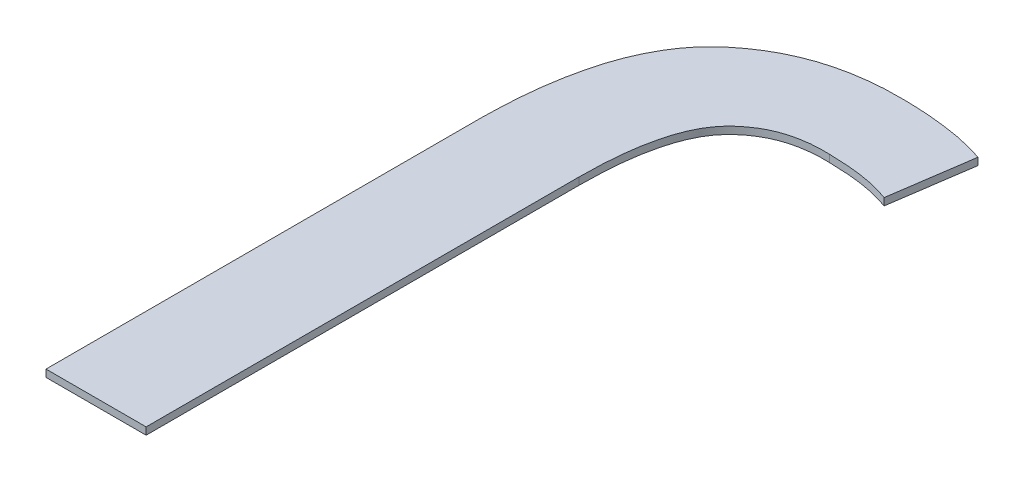
from build123d import *

# Parameters (mm, degrees)
EXTRUDE_1_DEPTH = 0.006


with BuildPart() as part:
    # Эскиз1 → Бобышка-Вытянуть1 (new body)
    with BuildSketch(Plane(origin=(0, 0, 0), x_dir=(1, 0, 0), z_dir=(0, 1, 0))):
        with BuildLine():
            Line((-0.552273294, -0.207212096), (-0.469416036, -0.207212096))
            Line((-0.469416036, -0.207212096), (-0.469416036, 0.15108915))
            add(Edge.make_bspline(
                [(-0.469416036, 0.15108915), (-0.469337668, 0.156710765), (-0.469187031, 0.167516567), (-0.468051363, 0.183019987), (-0.46630937, 0.197186892), (-0.463608191, 0.209875156), (-0.460547741, 0.221272508), (-0.456571693, 0.23120128), (-0.451914296, 0.239795103), (-0.446397888, 0.246954712), (-0.440258107, 0.252955311), (-0.433597544, 0.258071325), (-0.42638389, 0.262405578), (-0.418587315, 0.265910913), (-0.410168879, 0.268420499), (-0.401249065, 0.270140745), (-0.39178388, 0.27111474), (-0.385302473, 0.27097713), (-0.38196714, 0.270906316)],
                knots=[0, 0, 0, 0, 1.6863e-05, 3.2414e-05, 4.6615e-05, 5.9643e-05, 7.1304e-05, 8.1972e-05, 9.1656e-05, 0.000100534, 0.000108976, 0.000117344, 0.000125674, 0.00013417, 0.000142917, 0.000151963, 0.000161395, 0.000171395, 0.000171395, 0.000171395, 0.000171395], degree=3))
            add(Edge.make_bspline(
                [(-0.38196714, 0.270906316), (-0.376724267, 0.270742629), (-0.366722855, 0.270430378), (-0.352487182, 0.268821302), (-0.339787948, 0.266275374), (-0.332048262, 0.263667602), (-0.328395702, 0.262436926)],
                knots=[0, 0, 0, 0, 1.5731e-05, 3.0008e-05, 4.2936e-05, 5.449e-05, 5.449e-05, 5.449e-05, 5.449e-05], degree=3))
            Line((-0.328395702, 0.262436926), (-0.31847811, 0.330239773))
            add(Edge.make_bspline(
                [(-0.31847811, 0.330239773), (-0.320825798, 0.330991558), (-0.3256882, 0.332548615), (-0.333418866, 0.334595903), (-0.341857288, 0.336433721), (-0.354125933, 0.338423269), (-0.369943112, 0.340262822), (-0.382743691, 0.340624439), (-0.389109999, 0.340804288)],
                knots=[0, 0, 0, 0, 7.394e-06, 1.5315e-05, 2.3981e-05, 3.3292e-05, 5.2595e-05, 7.1694e-05, 7.1694e-05, 7.1694e-05, 7.1694e-05], degree=3))
            add(Edge.make_bspline(
                [(-0.389109999, 0.340804288), (-0.394998076, 0.340800326), (-0.406527444, 0.34079257), (-0.423393567, 0.339124687), (-0.439382173, 0.336197943), (-0.454537126, 0.331897822), (-0.468829459, 0.326183976), (-0.482280707, 0.319119391), (-0.494833003, 0.310665771), (-0.506548755, 0.300866426), (-0.517226948, 0.28936948), (-0.526323341, 0.27574323), (-0.534189517, 0.260273244), (-0.540589361, 0.242792298), (-0.545497563, 0.223351222), (-0.549276642, 0.201976128), (-0.551575084, 0.178573098), (-0.552034776, 0.16230595), (-0.552273294, 0.153865478)],
                knots=[0, 0, 0, 0, 1.7656e-05, 3.4571e-05, 5.0763e-05, 6.6363e-05, 8.1749e-05, 9.6857e-05, 0.000111857, 0.000127065, 0.000142591, 0.000158752, 0.000176048, 0.000194548, 0.000214471, 0.000236129, 0.000259614, 0.000284941, 0.000284941, 0.000284941, 0.000284941], degree=3))
            Line((-0.552273294, 0.153865478), (-0.552273294, -0.207212096))
        make_face()
    extrude(amount=EXTRUDE_1_DEPTH)


solid = part.part
